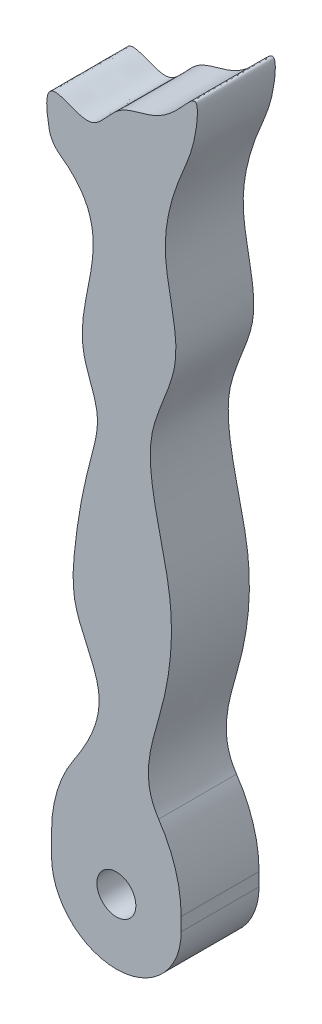
from build123d import *

# Parameters (mm, degrees)
SKETCH1_R           = 1.5
BOSS_EXTRUDE1_DEPTH = 6
FILLET1_R           = 10
FILLET2_R           = 2
FILLET3_R           = 2
CUT_EXTRUDE1_DEPTH  = 10


with BuildPart() as part:
    # Sketch1 → Boss-Extrude1 (new body)
    with BuildSketch(Plane.XY):
        with BuildLine():
            Line((0, 0), (0, -9.98))
            Line((0, -9.98), (9.98, -9.98))
            Line((9.98, -9.98), (9.98, 0))
            add(Edge.make_bspline(
                [(0, 42.597353519), (-1.374167764, 48.504645859), (2.718082532, 43.572691284), (4.828275202, 47.724320351), (7.807784172, 48.150888099), (9.443771335, 49.293582784), (11.362358663, 51.628459196), (11.106179162, 47.886697469), (9.743596874, 45.274160998), (7.960024069, 39.363127087), (10.708150912, 33.062193049), (7.469972977, 28.04695481), (7.684596065, 22.523119187), (9.645025029, 16.822172505), (8.8216478, 8.440308562), (6.053614063, 2.653026719), (9.98, 0)],
                knots=[0, 0, 0, 0, 0.081693532, 0.122819377, 0.160760334, 0.205378373, 0.226065167, 0.252136568, 0.308777769, 0.391029695, 0.500424409, 0.587678436, 0.631958896, 0.740886228, 0.85002552, 1, 1, 1, 1], degree=3))
            add(Edge.make_bspline(
                [(0, 42.597353519), (5.999175148, 38.977644411), (0.377371099, 32.788170927), (3.99264049, 26.388023766), (2.583653444, 21.790823594), (1.797916306, 17.414424542), (1.452593065, 12.093731472), (5.425983608, 6.836132729), (1.509712092, 2.017938291), (0, 0)],
                knots=[0, 0, 0, 0, 0.301224545, 0.380755768, 0.457986823, 0.608527536, 0.686337501, 0.807000811, 1, 1, 1, 1], degree=3))
        make_face()
        with Locations((4.99, -4.99)):
            Circle(SKETCH1_R, mode=Mode.SUBTRACT)
    extrude(amount=BOSS_EXTRUDE1_DEPTH)

    # Fillet1
    fillet1_edges = [part.edges().sort_by_distance(p)[0] for p in [
        (0, 0, 3),
        (9.98, 0, 3),
    ]]
    fillet(fillet1_edges, radius=FILLET1_R)

    # Fillet2
    fillet2_edges = [part.edges().sort_by_distance(p)[0] for p in [
        (0, 42.597353519, 3),
    ]]
    fillet(fillet2_edges, radius=FILLET2_R)

    # Fillet3
    fillet3_edges = [part.edges().sort_by_distance(p)[0] for p in [
        (0, -9.98, 3),
        (9.98, -9.98, 3),
    ]]
    fillet(fillet3_edges, radius=FILLET3_R)

    # Sketch2 → Cut-Extrude1 (cut)
    with BuildSketch(Plane.XY.offset(6)):
        with BuildLine():
            ThreePointArc((4.99, -9.98), (1.461537158, -8.518462834), (0, -4.989999988))
            Line((0, -4.989999988), (0, -7.98))
            ThreePointArc((0, -7.98), (0.585786438, -9.394213562), (2, -9.98))
            Line((2, -9.98), (4.99, -9.98))
        make_face()
        with BuildLine():
            Line((9.98, -7.98), (9.98, -4.99))
            ThreePointArc((9.98, -4.99), (8.518462838, -8.518462838), (4.99, -9.98))
            Line((4.99, -9.98), (7.98, -9.98))
            ThreePointArc((7.98, -9.98), (9.394213562, -9.394213562), (9.98, -7.98))
        make_face()
    extrude(amount=-CUT_EXTRUDE1_DEPTH, mode=Mode.SUBTRACT)


solid = part.part
